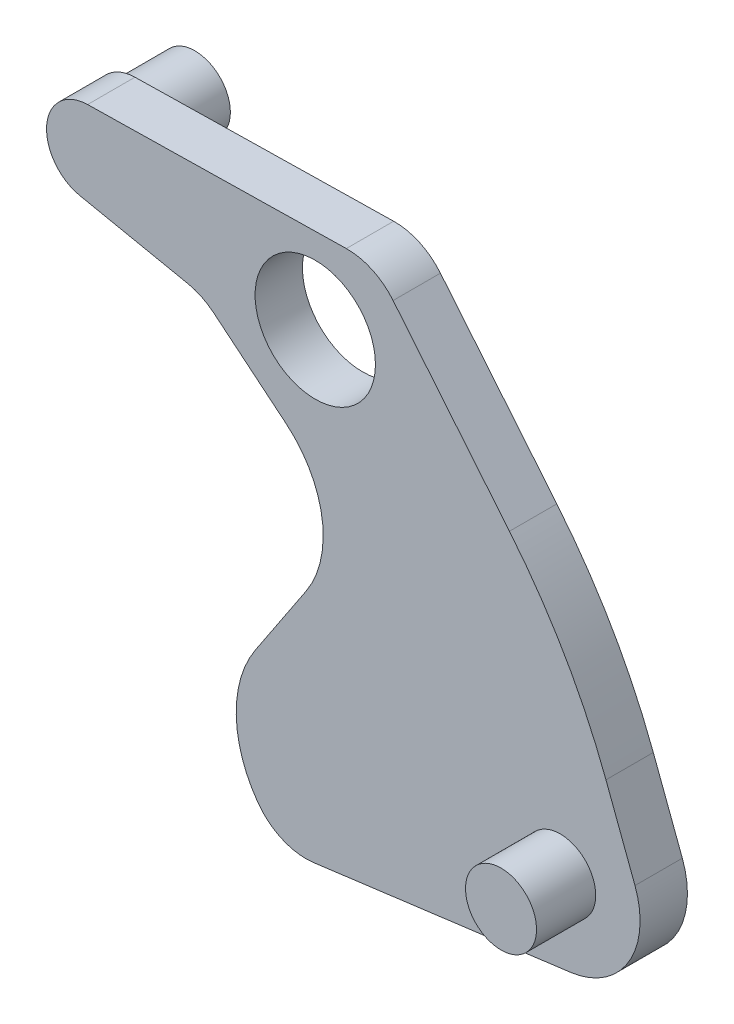
from build123d import *

# Parameters (mm, degrees)
BOSS_EXTRUDE1_DEPTH = 0.4
SKETCH2_W           = 0.3
SKETCH2_H           = 0.5
SKETCH3_W           = 0.3
SKETCH3_H           = 0.5
HOLE1_D             = 1.0170144
HOLE1_DEPTH         = 0.9
FILLET1_R           = 0.5
FILLET2_R           = 0.675116289
FILLET3_R           = 0.860966661
FILLET4_R           = 5


with BuildPart() as part:
    # Sketch1 → Boss-Extrude1 (new body)
    with BuildSketch(Plane(origin=(0, 0, 0), x_dir=(-1, 0, 0), z_dir=(0, 0, -1))):
        with BuildLine():
            Line((1.92357438, 0.686162269), (-0.504151468, 0.729490315))
            Line((-0.504151468, 0.729490315), (-2.165159681, -1.292473972))
            Line((-2.165159681, -1.292473972), (-3.001972093, -3.513959355))
            Line((-3.001972093, -3.513959355), (0.244519319, -3.936309209))
            ThreePointArc((0.244519319, -3.936309209), (0.65000118, -3.31960662), (0.50548708, -2.595829516))
            Line((0.50548708, -2.595829516), (-0.352902824, -1.303839102))
            Line((-0.352902824, -1.303839102), (0.955537124, -0.225531852))
            Line((0.955537124, -0.225531852), (1.988382035, -0.013355626))
            ThreePointArc((1.988382035, -0.013355626), (2.269162736, 0.365418669), (1.92357438, 0.686162269))
        make_face()
    extrude(amount=-BOSS_EXTRUDE1_DEPTH)

    # Sketch2 → Revolve1 (revolve)
    with BuildSketch(Plane.XZ.offset(2.954427416)):
        with Locations((2.219775702, 0.65)):
            Rectangle(SKETCH2_W, SKETCH2_H)
    revolve(axis=Axis((2.069775702, -2.954427416, 0.9), (0, 0, -1)))

    # Sketch3 → Revolve2 (revolve)
    with BuildSketch(Plane(origin=(0, 0.332816985, 0), x_dir=(1, 0, 0), z_dir=(0, 1, 0))):
        with Locations((-1.767268165, 0.25)):
            Rectangle(SKETCH3_W, SKETCH3_H)
    revolve(axis=Axis((-1.917268165, 0.332816985, -0.5), (0, 0, 1)))

    # Hole1
    with Locations(Plane.XY.offset(0.4)):
        with Locations((0, 0)):
            Hole(HOLE1_D / 2, depth=HOLE1_DEPTH)

    # Fillet1
    fillet1_edges = [part.edges().sort_by_distance(p)[0] for p in [
        (0.504151468, 0.729490315, 0.2),
        (-0.244519319, -3.936309209, 0.2),
        (-0.955537124, -0.225531852, 0.2),
    ]]
    fillet(fillet1_edges, radius=FILLET1_R)

    # Fillet2
    fillet2_edges = [part.edges().sort_by_distance(p)[0] for p in [
        (3.001972093, -3.513959355, 0.2),
    ]]
    fillet(fillet2_edges, radius=FILLET2_R)

    # Fillet3
    fillet3_edges = [part.edges().sort_by_distance(p)[0] for p in [
        (0.352902824, -1.303839102, 0.2),
    ]]
    fillet(fillet3_edges, radius=FILLET3_R)

    # Fillet4
    fillet4_edges = [part.edges().sort_by_distance(p)[0] for p in [
        (2.165159681, -1.292473972, 0.2),
    ]]
    fillet(fillet4_edges, radius=FILLET4_R)


solid = part.part
